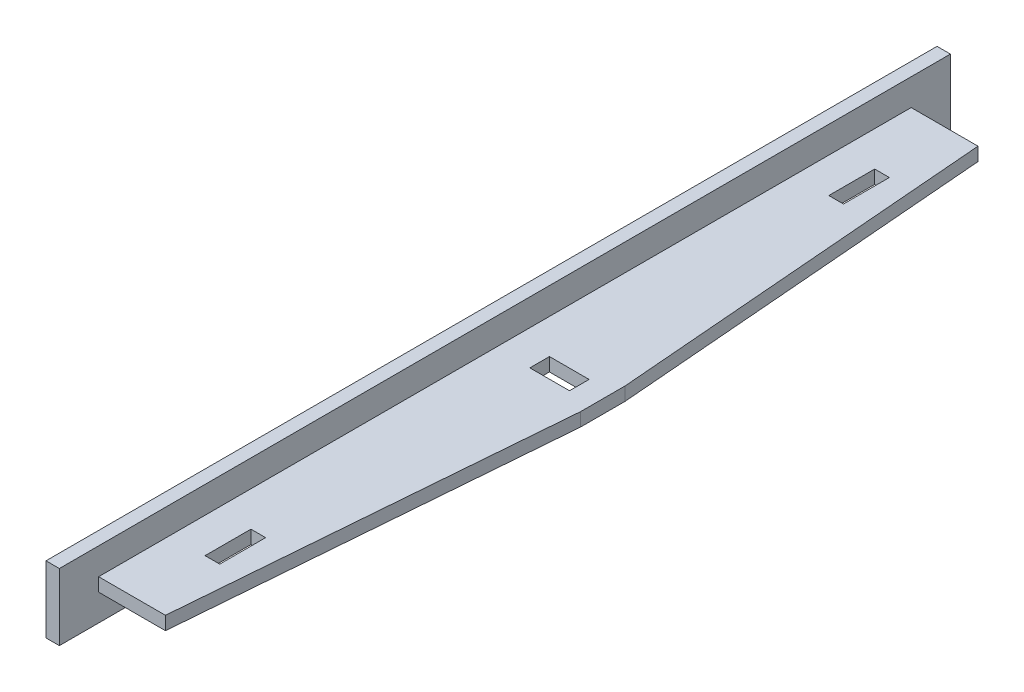
from build123d import *

# Parameters (mm, degrees)
SKETCH_1_W          = 3
SKETCH_1_H          = 15
EXTRUDE_1_DEPTH     = 200
EXTRUDE_7_DEPTH     = 3
SKETCH_13_W         = 3.3
SKETCH_13_H         = 10.3
SKETCH_13_W_2       = 8.9
SKETCH_13_H_2       = 4.4
CUT_EXTRUDE_1_DEPTH = 10


with BuildPart() as part:
    # 草图1 → 凸台-拉伸1 (new body)
    with BuildSketch(Plane.XY):
        with Locations((1.5, 7.5)):
            Rectangle(SKETCH_1_W, SKETCH_1_H)
    extrude(amount=EXTRUDE_1_DEPTH)

    # 草图12 → 凸台-拉伸7 (add)
    with BuildSketch(Plane(origin=(0, 9, 0), x_dir=(1, 0, 0), z_dir=(0, 1, 0))):
        Polygon((18, -191.190016229), (25, -105), (25, -95), (18, -8.809983771), (3, -8.809983771), (3, -191.190016229), align=None)
    extrude(amount=-EXTRUDE_7_DEPTH)

    # 草图13 → 切除-拉伸1 (cut)
    with BuildSketch(Plane.XZ.offset(-6)):
        with Locations((12.5, 29.999983771)):
            Rectangle(SKETCH_13_W, SKETCH_13_H)
        with Locations((12.5, 169.999983771)):
            Rectangle(SKETCH_13_W, SKETCH_13_H)
        with Locations((15.25, 99.999983771)):
            Rectangle(SKETCH_13_W_2, SKETCH_13_H_2)
    extrude(amount=-CUT_EXTRUDE_1_DEPTH, mode=Mode.SUBTRACT)


solid = part.part
